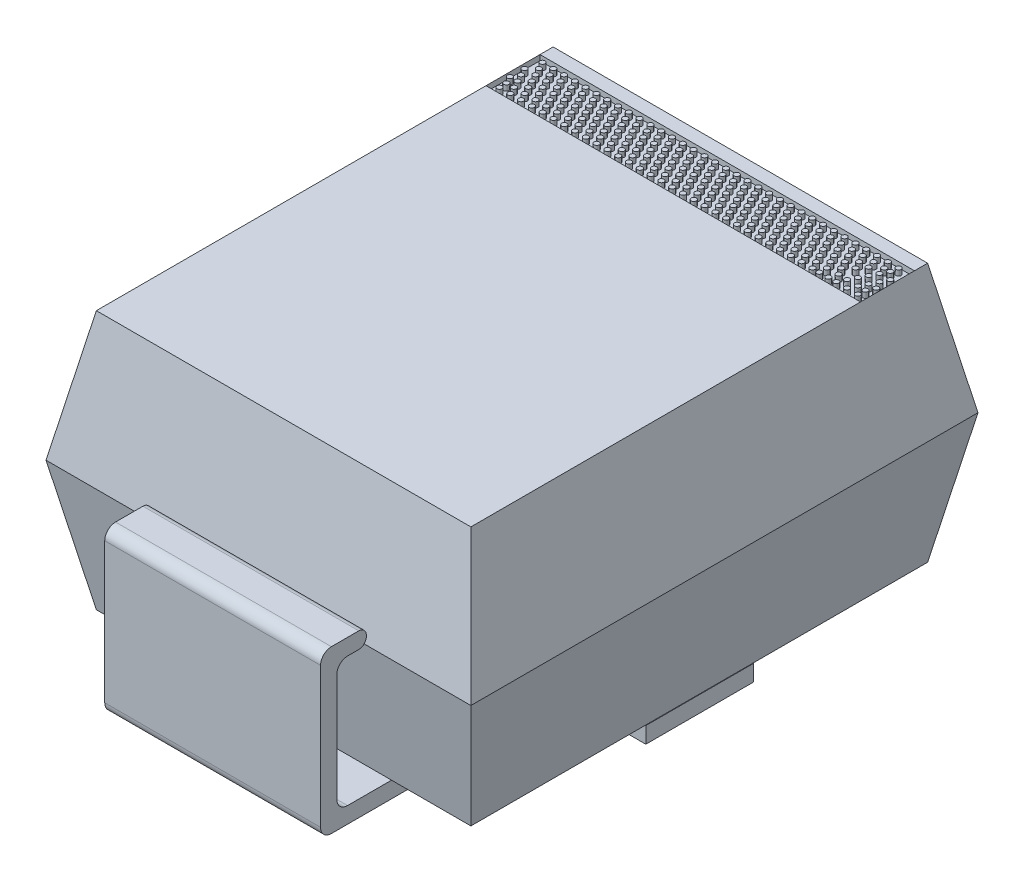
from build123d import *

# Parameters (mm, degrees)
CROQUIS9_W                        = 3.937
CROQUIS9_H                        = 4.699
SALIENTE_EXTRUIR3_DEPTH           = 1.2
SALIENTE_EXTRUIR3_TAPER           = 11
SALIENTE_EXTRUIR3_OTHER_WAY_DEPTH = 1.2
SALIENTE_EXTRUIR3_OTHER_WAY_TAPER = 11
CROQUIS10_W                       = 3.470487258
CROQUIS10_H                       = 0.5
CROQUIS10_R                       = 0.023553364
CROQUIS10_R_2                     = 0.023356671
CORTAR_EXTRUIR2_DEPTH             = 0.05
CROQUIS12_W                       = 1
CROQUIS12_H                       = 0.15
SALIENTE_EXTRUIR4_DEPTH           = 1.74
SALIENTE_EXTRUIR5_DEPTH           = 1


with BuildPart() as part:
    # Croquis9 → Saliente-Extruir3 (new body)
    with BuildSketch(Plane(origin=(0, 0, 0), x_dir=(1, 0, 0), z_dir=(0, 1, 0))):
        Rectangle(CROQUIS9_W, CROQUIS9_H)
    extrude(amount=SALIENTE_EXTRUIR3_DEPTH, taper=SALIENTE_EXTRUIR3_TAPER)

    # Croquis9 → Saliente-Extruir3 other way (add)
    with BuildSketch(Plane(origin=(0, 0, 0), x_dir=(1, 0, 0), z_dir=(0, 1, 0))):
        Rectangle(CROQUIS9_W, CROQUIS9_H)
    extrude(amount=-SALIENTE_EXTRUIR3_OTHER_WAY_DEPTH, taper=SALIENTE_EXTRUIR3_OTHER_WAY_TAPER)

    # Croquis10 → Cortar-Extruir2 (cut)
    with BuildSketch(Plane(origin=(0, 1.2, 0), x_dir=(1, 0, 0), z_dir=(0, 1, 0))):
        with Locations((0, 1.744170345)):
            Rectangle(CROQUIS10_W, CROQUIS10_H)
        with Locations((-1.6601337, 1.544634808)):
            Circle(CROQUIS10_R, mode=Mode.SUBTRACT)
        with Locations((-1.593661989, 1.611140272)):
            Circle(CROQUIS10_R, mode=Mode.SUBTRACT)
        with Locations((-1.527190278, 1.677645736)):
            Circle(CROQUIS10_R, mode=Mode.SUBTRACT)
        with Locations((-1.460718567, 1.7441512)):
            Circle(CROQUIS10_R, mode=Mode.SUBTRACT)
        with Locations((-1.394246856, 1.810656664)):
            Circle(CROQUIS10_R, mode=Mode.SUBTRACT)
        with Locations((-1.327775145, 1.877162128)):
            Circle(CROQUIS10_R, mode=Mode.SUBTRACT)
        with Locations((-1.261303434, 1.943667592)):
            Circle(CROQUIS10_R, mode=Mode.SUBTRACT)
        with Locations((-1.493661989, 1.611140272)):
            Circle(CROQUIS10_R, mode=Mode.SUBTRACT)
        with Locations((-1.5601337, 1.544634808)):
            Circle(CROQUIS10_R, mode=Mode.SUBTRACT)
        with Locations((-1.427190278, 1.677645736)):
            Circle(CROQUIS10_R, mode=Mode.SUBTRACT)
        with Locations((-1.360718567, 1.7441512)):
            Circle(CROQUIS10_R, mode=Mode.SUBTRACT)
        with Locations((-1.294246856, 1.810656664)):
            Circle(CROQUIS10_R, mode=Mode.SUBTRACT)
        with Locations((-1.227775145, 1.877162128)):
            Circle(CROQUIS10_R, mode=Mode.SUBTRACT)
        with Locations((-1.161303434, 1.943667592)):
            Circle(CROQUIS10_R, mode=Mode.SUBTRACT)
        with Locations((-1.393661989, 1.611140272)):
            Circle(CROQUIS10_R, mode=Mode.SUBTRACT)
        with Locations((-1.4601337, 1.544634808)):
            Circle(CROQUIS10_R, mode=Mode.SUBTRACT)
        with Locations((-1.327190278, 1.677645736)):
            Circle(CROQUIS10_R, mode=Mode.SUBTRACT)
        with Locations((-1.260718567, 1.7441512)):
            Circle(CROQUIS10_R, mode=Mode.SUBTRACT)
        with Locations((-1.194246856, 1.810656664)):
            Circle(CROQUIS10_R, mode=Mode.SUBTRACT)
        with Locations((-1.127775145, 1.877162128)):
            Circle(CROQUIS10_R, mode=Mode.SUBTRACT)
        with Locations((-1.061303434, 1.943667592)):
            Circle(CROQUIS10_R, mode=Mode.SUBTRACT)
        with Locations((-1.293661989, 1.611140272)):
            Circle(CROQUIS10_R, mode=Mode.SUBTRACT)
        with Locations((-1.3601337, 1.544634808)):
            Circle(CROQUIS10_R, mode=Mode.SUBTRACT)
        with Locations((-1.227190278, 1.677645736)):
            Circle(CROQUIS10_R, mode=Mode.SUBTRACT)
        with Locations((-1.160718567, 1.7441512)):
            Circle(CROQUIS10_R, mode=Mode.SUBTRACT)
        with Locations((-1.094246856, 1.810656664)):
            Circle(CROQUIS10_R, mode=Mode.SUBTRACT)
        with Locations((-1.027775145, 1.877162128)):
            Circle(CROQUIS10_R, mode=Mode.SUBTRACT)
        with Locations((-0.961303434, 1.943667592)):
            Circle(CROQUIS10_R, mode=Mode.SUBTRACT)
        with Locations((-1.193661989, 1.611140272)):
            Circle(CROQUIS10_R, mode=Mode.SUBTRACT)
        with Locations((-1.2601337, 1.544634808)):
            Circle(CROQUIS10_R, mode=Mode.SUBTRACT)
        with Locations((-1.127190278, 1.677645736)):
            Circle(CROQUIS10_R, mode=Mode.SUBTRACT)
        with Locations((-1.060718567, 1.7441512)):
            Circle(CROQUIS10_R, mode=Mode.SUBTRACT)
        with Locations((-0.994246856, 1.810656664)):
            Circle(CROQUIS10_R, mode=Mode.SUBTRACT)
        with Locations((-0.927775145, 1.877162128)):
            Circle(CROQUIS10_R, mode=Mode.SUBTRACT)
        with Locations((-0.861303434, 1.943667592)):
            Circle(CROQUIS10_R, mode=Mode.SUBTRACT)
        with Locations((-1.093661989, 1.611140272)):
            Circle(CROQUIS10_R, mode=Mode.SUBTRACT)
        with Locations((-1.1601337, 1.544634808)):
            Circle(CROQUIS10_R, mode=Mode.SUBTRACT)
        with Locations((-1.027190278, 1.677645736)):
            Circle(CROQUIS10_R, mode=Mode.SUBTRACT)
        with Locations((-0.960718567, 1.7441512)):
            Circle(CROQUIS10_R, mode=Mode.SUBTRACT)
        with Locations((-0.894246856, 1.810656664)):
            Circle(CROQUIS10_R, mode=Mode.SUBTRACT)
        with Locations((-0.827775145, 1.877162128)):
            Circle(CROQUIS10_R, mode=Mode.SUBTRACT)
        with Locations((-0.761303434, 1.943667592)):
            Circle(CROQUIS10_R, mode=Mode.SUBTRACT)
        with Locations((-0.993661989, 1.611140272)):
            Circle(CROQUIS10_R, mode=Mode.SUBTRACT)
        with Locations((-1.0601337, 1.544634808)):
            Circle(CROQUIS10_R, mode=Mode.SUBTRACT)
        with Locations((-0.927190278, 1.677645736)):
            Circle(CROQUIS10_R, mode=Mode.SUBTRACT)
        with Locations((-0.860718567, 1.7441512)):
            Circle(CROQUIS10_R, mode=Mode.SUBTRACT)
        with Locations((-0.794246856, 1.810656664)):
            Circle(CROQUIS10_R, mode=Mode.SUBTRACT)
        with Locations((-0.727775145, 1.877162128)):
            Circle(CROQUIS10_R, mode=Mode.SUBTRACT)
        with Locations((-0.661303434, 1.943667592)):
            Circle(CROQUIS10_R, mode=Mode.SUBTRACT)
        with Locations((-0.893661989, 1.611140272)):
            Circle(CROQUIS10_R, mode=Mode.SUBTRACT)
        with Locations((-0.9601337, 1.544634808)):
            Circle(CROQUIS10_R, mode=Mode.SUBTRACT)
        with Locations((-0.827190278, 1.677645736)):
            Circle(CROQUIS10_R, mode=Mode.SUBTRACT)
        with Locations((-0.760718567, 1.7441512)):
            Circle(CROQUIS10_R, mode=Mode.SUBTRACT)
        with Locations((-0.694246856, 1.810656664)):
            Circle(CROQUIS10_R, mode=Mode.SUBTRACT)
        with Locations((-0.627775145, 1.877162128)):
            Circle(CROQUIS10_R, mode=Mode.SUBTRACT)
        with Locations((-0.561303434, 1.943667592)):
            Circle(CROQUIS10_R, mode=Mode.SUBTRACT)
        with Locations((-0.793661989, 1.611140272)):
            Circle(CROQUIS10_R, mode=Mode.SUBTRACT)
        with Locations((-0.8601337, 1.544634808)):
            Circle(CROQUIS10_R, mode=Mode.SUBTRACT)
        with Locations((-0.727190278, 1.677645736)):
            Circle(CROQUIS10_R, mode=Mode.SUBTRACT)
        with Locations((-0.660718567, 1.7441512)):
            Circle(CROQUIS10_R, mode=Mode.SUBTRACT)
        with Locations((-0.594246856, 1.810656664)):
            Circle(CROQUIS10_R, mode=Mode.SUBTRACT)
        with Locations((-0.527775145, 1.877162128)):
            Circle(CROQUIS10_R, mode=Mode.SUBTRACT)
        with Locations((-0.461303434, 1.943667592)):
            Circle(CROQUIS10_R, mode=Mode.SUBTRACT)
        with Locations((-0.693661989, 1.611140272)):
            Circle(CROQUIS10_R, mode=Mode.SUBTRACT)
        with Locations((-0.7601337, 1.544634808)):
            Circle(CROQUIS10_R, mode=Mode.SUBTRACT)
        with Locations((-0.627190278, 1.677645736)):
            Circle(CROQUIS10_R, mode=Mode.SUBTRACT)
        with Locations((-0.560718567, 1.7441512)):
            Circle(CROQUIS10_R, mode=Mode.SUBTRACT)
        with Locations((-0.494246856, 1.810656664)):
            Circle(CROQUIS10_R, mode=Mode.SUBTRACT)
        with Locations((-0.427775145, 1.877162128)):
            Circle(CROQUIS10_R, mode=Mode.SUBTRACT)
        with Locations((-0.361303434, 1.943667592)):
            Circle(CROQUIS10_R, mode=Mode.SUBTRACT)
        with Locations((-0.593661989, 1.611140272)):
            Circle(CROQUIS10_R, mode=Mode.SUBTRACT)
        with Locations((-0.6601337, 1.544634808)):
            Circle(CROQUIS10_R, mode=Mode.SUBTRACT)
        with Locations((-0.527190278, 1.677645736)):
            Circle(CROQUIS10_R, mode=Mode.SUBTRACT)
        with Locations((-0.460718567, 1.7441512)):
            Circle(CROQUIS10_R, mode=Mode.SUBTRACT)
        with Locations((-0.394246856, 1.810656664)):
            Circle(CROQUIS10_R, mode=Mode.SUBTRACT)
        with Locations((-0.327775145, 1.877162128)):
            Circle(CROQUIS10_R, mode=Mode.SUBTRACT)
        with Locations((-0.261303434, 1.943667592)):
            Circle(CROQUIS10_R, mode=Mode.SUBTRACT)
        with Locations((-0.493661989, 1.611140272)):
            Circle(CROQUIS10_R, mode=Mode.SUBTRACT)
        with Locations((-0.5601337, 1.544634808)):
            Circle(CROQUIS10_R, mode=Mode.SUBTRACT)
        with Locations((-0.427190278, 1.677645736)):
            Circle(CROQUIS10_R, mode=Mode.SUBTRACT)
        with Locations((-0.360718567, 1.7441512)):
            Circle(CROQUIS10_R, mode=Mode.SUBTRACT)
        with Locations((-0.294246856, 1.810656664)):
            Circle(CROQUIS10_R, mode=Mode.SUBTRACT)
        with Locations((-0.227775145, 1.877162128)):
            Circle(CROQUIS10_R, mode=Mode.SUBTRACT)
        with Locations((-0.161303434, 1.943667592)):
            Circle(CROQUIS10_R, mode=Mode.SUBTRACT)
        with Locations((-0.393661989, 1.611140272)):
            Circle(CROQUIS10_R, mode=Mode.SUBTRACT)
        with Locations((-0.4601337, 1.544634808)):
            Circle(CROQUIS10_R, mode=Mode.SUBTRACT)
        with Locations((-0.327190278, 1.677645736)):
            Circle(CROQUIS10_R, mode=Mode.SUBTRACT)
        with Locations((-0.260718567, 1.7441512)):
            Circle(CROQUIS10_R, mode=Mode.SUBTRACT)
        with Locations((-0.194246856, 1.810656664)):
            Circle(CROQUIS10_R, mode=Mode.SUBTRACT)
        with Locations((-0.127775145, 1.877162128)):
            Circle(CROQUIS10_R, mode=Mode.SUBTRACT)
        with Locations((-0.061303434, 1.943667592)):
            Circle(CROQUIS10_R, mode=Mode.SUBTRACT)
        with Locations((-0.293661989, 1.611140272)):
            Circle(CROQUIS10_R, mode=Mode.SUBTRACT)
        with Locations((-0.3601337, 1.544634808)):
            Circle(CROQUIS10_R, mode=Mode.SUBTRACT)
        with Locations((-0.227190278, 1.677645736)):
            Circle(CROQUIS10_R, mode=Mode.SUBTRACT)
        with Locations((-0.160718567, 1.7441512)):
            Circle(CROQUIS10_R, mode=Mode.SUBTRACT)
        with Locations((-0.094246856, 1.810656664)):
            Circle(CROQUIS10_R, mode=Mode.SUBTRACT)
        with Locations((-0.027775145, 1.877162128)):
            Circle(CROQUIS10_R, mode=Mode.SUBTRACT)
        with Locations((0.038696566, 1.943667592)):
            Circle(CROQUIS10_R, mode=Mode.SUBTRACT)
        with Locations((-0.193661989, 1.611140272)):
            Circle(CROQUIS10_R, mode=Mode.SUBTRACT)
        with Locations((-0.2601337, 1.544634808)):
            Circle(CROQUIS10_R, mode=Mode.SUBTRACT)
        with Locations((-0.127190278, 1.677645736)):
            Circle(CROQUIS10_R, mode=Mode.SUBTRACT)
        with Locations((-0.060718567, 1.7441512)):
            Circle(CROQUIS10_R, mode=Mode.SUBTRACT)
        with Locations((0.005753144, 1.810656664)):
            Circle(CROQUIS10_R, mode=Mode.SUBTRACT)
        with Locations((0.072224855, 1.877162128)):
            Circle(CROQUIS10_R, mode=Mode.SUBTRACT)
        with Locations((0.138696566, 1.943667592)):
            Circle(CROQUIS10_R, mode=Mode.SUBTRACT)
        with Locations((-0.093661989, 1.611140272)):
            Circle(CROQUIS10_R, mode=Mode.SUBTRACT)
        with Locations((-0.1601337, 1.544634808)):
            Circle(CROQUIS10_R, mode=Mode.SUBTRACT)
        with Locations((-0.027190278, 1.677645736)):
            Circle(CROQUIS10_R, mode=Mode.SUBTRACT)
        with Locations((0.039281433, 1.7441512)):
            Circle(CROQUIS10_R, mode=Mode.SUBTRACT)
        with Locations((0.105753144, 1.810656664)):
            Circle(CROQUIS10_R, mode=Mode.SUBTRACT)
        with Locations((0.172224855, 1.877162128)):
            Circle(CROQUIS10_R, mode=Mode.SUBTRACT)
        with Locations((0.238696566, 1.943667592)):
            Circle(CROQUIS10_R, mode=Mode.SUBTRACT)
        with Locations((0.006338011, 1.611140272)):
            Circle(CROQUIS10_R, mode=Mode.SUBTRACT)
        with Locations((-0.0601337, 1.544634808)):
            Circle(CROQUIS10_R, mode=Mode.SUBTRACT)
        with Locations((0.072809722, 1.677645736)):
            Circle(CROQUIS10_R, mode=Mode.SUBTRACT)
        with Locations((0.139281433, 1.7441512)):
            Circle(CROQUIS10_R, mode=Mode.SUBTRACT)
        with Locations((0.205753144, 1.810656664)):
            Circle(CROQUIS10_R, mode=Mode.SUBTRACT)
        with Locations((0.272224855, 1.877162128)):
            Circle(CROQUIS10_R, mode=Mode.SUBTRACT)
        with Locations((0.338696566, 1.943667592)):
            Circle(CROQUIS10_R, mode=Mode.SUBTRACT)
        with Locations((0.106338011, 1.611140272)):
            Circle(CROQUIS10_R, mode=Mode.SUBTRACT)
        with Locations((0.0398663, 1.544634808)):
            Circle(CROQUIS10_R, mode=Mode.SUBTRACT)
        with Locations((0.172809722, 1.677645736)):
            Circle(CROQUIS10_R, mode=Mode.SUBTRACT)
        with Locations((0.239281433, 1.7441512)):
            Circle(CROQUIS10_R, mode=Mode.SUBTRACT)
        with Locations((0.305753144, 1.810656664)):
            Circle(CROQUIS10_R, mode=Mode.SUBTRACT)
        with Locations((0.372224855, 1.877162128)):
            Circle(CROQUIS10_R, mode=Mode.SUBTRACT)
        with Locations((0.438696566, 1.943667592)):
            Circle(CROQUIS10_R, mode=Mode.SUBTRACT)
        with Locations((0.206338011, 1.611140272)):
            Circle(CROQUIS10_R, mode=Mode.SUBTRACT)
        with Locations((0.1398663, 1.544634808)):
            Circle(CROQUIS10_R, mode=Mode.SUBTRACT)
        with Locations((0.272809722, 1.677645736)):
            Circle(CROQUIS10_R, mode=Mode.SUBTRACT)
        with Locations((0.339281433, 1.7441512)):
            Circle(CROQUIS10_R, mode=Mode.SUBTRACT)
        with Locations((0.405753144, 1.810656664)):
            Circle(CROQUIS10_R, mode=Mode.SUBTRACT)
        with Locations((0.472224855, 1.877162128)):
            Circle(CROQUIS10_R, mode=Mode.SUBTRACT)
        with Locations((0.538696566, 1.943667592)):
            Circle(CROQUIS10_R, mode=Mode.SUBTRACT)
        with Locations((0.306338011, 1.611140272)):
            Circle(CROQUIS10_R, mode=Mode.SUBTRACT)
        with Locations((0.2398663, 1.544634808)):
            Circle(CROQUIS10_R, mode=Mode.SUBTRACT)
        with Locations((0.372809722, 1.677645736)):
            Circle(CROQUIS10_R, mode=Mode.SUBTRACT)
        with Locations((0.439281433, 1.7441512)):
            Circle(CROQUIS10_R, mode=Mode.SUBTRACT)
        with Locations((0.505753144, 1.810656664)):
            Circle(CROQUIS10_R, mode=Mode.SUBTRACT)
        with Locations((0.572224855, 1.877162128)):
            Circle(CROQUIS10_R, mode=Mode.SUBTRACT)
        with Locations((0.638696566, 1.943667592)):
            Circle(CROQUIS10_R, mode=Mode.SUBTRACT)
        with Locations((0.406338011, 1.611140272)):
            Circle(CROQUIS10_R, mode=Mode.SUBTRACT)
        with Locations((0.3398663, 1.544634808)):
            Circle(CROQUIS10_R, mode=Mode.SUBTRACT)
        with Locations((0.472809722, 1.677645736)):
            Circle(CROQUIS10_R, mode=Mode.SUBTRACT)
        with Locations((0.539281433, 1.7441512)):
            Circle(CROQUIS10_R, mode=Mode.SUBTRACT)
        with Locations((0.605753144, 1.810656664)):
            Circle(CROQUIS10_R, mode=Mode.SUBTRACT)
        with Locations((0.672224855, 1.877162128)):
            Circle(CROQUIS10_R, mode=Mode.SUBTRACT)
        with Locations((0.738696566, 1.943667592)):
            Circle(CROQUIS10_R, mode=Mode.SUBTRACT)
        with Locations((0.506338011, 1.611140272)):
            Circle(CROQUIS10_R, mode=Mode.SUBTRACT)
        with Locations((0.4398663, 1.544634808)):
            Circle(CROQUIS10_R, mode=Mode.SUBTRACT)
        with Locations((0.572809722, 1.677645736)):
            Circle(CROQUIS10_R, mode=Mode.SUBTRACT)
        with Locations((0.639281433, 1.7441512)):
            Circle(CROQUIS10_R, mode=Mode.SUBTRACT)
        with Locations((0.705753144, 1.810656664)):
            Circle(CROQUIS10_R, mode=Mode.SUBTRACT)
        with Locations((0.772224855, 1.877162128)):
            Circle(CROQUIS10_R, mode=Mode.SUBTRACT)
        with Locations((0.838696566, 1.943667592)):
            Circle(CROQUIS10_R, mode=Mode.SUBTRACT)
        with Locations((0.606338011, 1.611140272)):
            Circle(CROQUIS10_R, mode=Mode.SUBTRACT)
        with Locations((0.5398663, 1.544634808)):
            Circle(CROQUIS10_R, mode=Mode.SUBTRACT)
        with Locations((0.672809722, 1.677645736)):
            Circle(CROQUIS10_R, mode=Mode.SUBTRACT)
        with Locations((0.739281433, 1.7441512)):
            Circle(CROQUIS10_R, mode=Mode.SUBTRACT)
        with Locations((0.805753144, 1.810656664)):
            Circle(CROQUIS10_R, mode=Mode.SUBTRACT)
        with Locations((0.872224855, 1.877162128)):
            Circle(CROQUIS10_R, mode=Mode.SUBTRACT)
        with Locations((0.938696566, 1.943667592)):
            Circle(CROQUIS10_R, mode=Mode.SUBTRACT)
        with Locations((0.706338011, 1.611140272)):
            Circle(CROQUIS10_R, mode=Mode.SUBTRACT)
        with Locations((0.6398663, 1.544634808)):
            Circle(CROQUIS10_R, mode=Mode.SUBTRACT)
        with Locations((0.772809722, 1.677645736)):
            Circle(CROQUIS10_R, mode=Mode.SUBTRACT)
        with Locations((0.839281433, 1.7441512)):
            Circle(CROQUIS10_R, mode=Mode.SUBTRACT)
        with Locations((0.905753144, 1.810656664)):
            Circle(CROQUIS10_R, mode=Mode.SUBTRACT)
        with Locations((0.972224855, 1.877162128)):
            Circle(CROQUIS10_R, mode=Mode.SUBTRACT)
        with Locations((1.038696566, 1.943667592)):
            Circle(CROQUIS10_R, mode=Mode.SUBTRACT)
        with Locations((0.806338011, 1.611140272)):
            Circle(CROQUIS10_R, mode=Mode.SUBTRACT)
        with Locations((0.7398663, 1.544634808)):
            Circle(CROQUIS10_R, mode=Mode.SUBTRACT)
        with Locations((0.872809722, 1.677645736)):
            Circle(CROQUIS10_R, mode=Mode.SUBTRACT)
        with Locations((0.939281433, 1.7441512)):
            Circle(CROQUIS10_R, mode=Mode.SUBTRACT)
        with Locations((1.005753144, 1.810656664)):
            Circle(CROQUIS10_R, mode=Mode.SUBTRACT)
        with Locations((1.072224855, 1.877162128)):
            Circle(CROQUIS10_R, mode=Mode.SUBTRACT)
        with Locations((1.138696566, 1.943667592)):
            Circle(CROQUIS10_R, mode=Mode.SUBTRACT)
        with Locations((0.906338011, 1.611140272)):
            Circle(CROQUIS10_R, mode=Mode.SUBTRACT)
        with Locations((0.8398663, 1.544634808)):
            Circle(CROQUIS10_R, mode=Mode.SUBTRACT)
        with Locations((0.972809722, 1.677645736)):
            Circle(CROQUIS10_R, mode=Mode.SUBTRACT)
        with Locations((1.039281433, 1.7441512)):
            Circle(CROQUIS10_R, mode=Mode.SUBTRACT)
        with Locations((1.105753144, 1.810656664)):
            Circle(CROQUIS10_R, mode=Mode.SUBTRACT)
        with Locations((1.172224855, 1.877162128)):
            Circle(CROQUIS10_R, mode=Mode.SUBTRACT)
        with Locations((1.238696566, 1.943667592)):
            Circle(CROQUIS10_R, mode=Mode.SUBTRACT)
        with Locations((1.006338011, 1.611140272)):
            Circle(CROQUIS10_R, mode=Mode.SUBTRACT)
        with Locations((0.9398663, 1.544634808)):
            Circle(CROQUIS10_R, mode=Mode.SUBTRACT)
        with Locations((1.072809722, 1.677645736)):
            Circle(CROQUIS10_R, mode=Mode.SUBTRACT)
        with Locations((1.139281433, 1.7441512)):
            Circle(CROQUIS10_R, mode=Mode.SUBTRACT)
        with Locations((1.205753144, 1.810656664)):
            Circle(CROQUIS10_R, mode=Mode.SUBTRACT)
        with Locations((1.272224855, 1.877162128)):
            Circle(CROQUIS10_R, mode=Mode.SUBTRACT)
        with Locations((1.338696566, 1.943667592)):
            Circle(CROQUIS10_R, mode=Mode.SUBTRACT)
        with Locations((1.106338011, 1.611140272)):
            Circle(CROQUIS10_R, mode=Mode.SUBTRACT)
        with Locations((1.0398663, 1.544634808)):
            Circle(CROQUIS10_R, mode=Mode.SUBTRACT)
        with Locations((1.172809722, 1.677645736)):
            Circle(CROQUIS10_R, mode=Mode.SUBTRACT)
        with Locations((1.239281433, 1.7441512)):
            Circle(CROQUIS10_R, mode=Mode.SUBTRACT)
        with Locations((1.305753144, 1.810656664)):
            Circle(CROQUIS10_R, mode=Mode.SUBTRACT)
        with Locations((1.372224855, 1.877162128)):
            Circle(CROQUIS10_R, mode=Mode.SUBTRACT)
        with Locations((1.438696566, 1.943667592)):
            Circle(CROQUIS10_R, mode=Mode.SUBTRACT)
        with Locations((1.206338011, 1.611140272)):
            Circle(CROQUIS10_R, mode=Mode.SUBTRACT)
        with Locations((1.1398663, 1.544634808)):
            Circle(CROQUIS10_R, mode=Mode.SUBTRACT)
        with Locations((1.272809722, 1.677645736)):
            Circle(CROQUIS10_R, mode=Mode.SUBTRACT)
        with Locations((1.339281433, 1.7441512)):
            Circle(CROQUIS10_R, mode=Mode.SUBTRACT)
        with Locations((1.405753144, 1.810656664)):
            Circle(CROQUIS10_R, mode=Mode.SUBTRACT)
        with Locations((1.472224855, 1.877162128)):
            Circle(CROQUIS10_R, mode=Mode.SUBTRACT)
        with Locations((1.538696566, 1.943667592)):
            Circle(CROQUIS10_R, mode=Mode.SUBTRACT)
        with Locations((1.306338011, 1.611140272)):
            Circle(CROQUIS10_R, mode=Mode.SUBTRACT)
        with Locations((1.2398663, 1.544634808)):
            Circle(CROQUIS10_R, mode=Mode.SUBTRACT)
        with Locations((1.372809722, 1.677645736)):
            Circle(CROQUIS10_R, mode=Mode.SUBTRACT)
        with Locations((1.439281433, 1.7441512)):
            Circle(CROQUIS10_R, mode=Mode.SUBTRACT)
        with Locations((1.305753144, 1.541401411)):
            Circle(CROQUIS10_R, mode=Mode.SUBTRACT)
        with Locations((1.572224855, 1.877162128)):
            Circle(CROQUIS10_R, mode=Mode.SUBTRACT)
        with Locations((1.638696566, 1.943667592)):
            Circle(CROQUIS10_R, mode=Mode.SUBTRACT)
        with Locations((-1.427775145, 1.877162128)):
            Circle(CROQUIS10_R, mode=Mode.SUBTRACT)
        with Locations((-1.361303434, 1.943667592)):
            Circle(CROQUIS10_R, mode=Mode.SUBTRACT)
        with Locations((-1.494246856, 1.810656664)):
            Circle(CROQUIS10_R, mode=Mode.SUBTRACT)
        with Locations((-1.560718567, 1.7441512)):
            Circle(CROQUIS10_R, mode=Mode.SUBTRACT)
        with Locations((-1.527775145, 1.877162128)):
            Circle(CROQUIS10_R, mode=Mode.SUBTRACT)
        with Locations((-1.461303434, 1.943667592)):
            Circle(CROQUIS10_R, mode=Mode.SUBTRACT)
        with Locations((-1.594246856, 1.810656664)):
            Circle(CROQUIS10_R, mode=Mode.SUBTRACT)
        with Locations((-1.694246856, 1.810656664)):
            Circle(CROQUIS10_R, mode=Mode.SUBTRACT)
        with Locations((-1.660718567, 1.7441512)):
            Circle(CROQUIS10_R, mode=Mode.SUBTRACT)
        with Locations((-1.627775145, 1.877162128)):
            Circle(CROQUIS10_R, mode=Mode.SUBTRACT)
        with Locations((-1.561303434, 1.943667592)):
            Circle(CROQUIS10_R, mode=Mode.SUBTRACT)
        with Locations((-1.627190278, 1.677645736)):
            Circle(CROQUIS10_R, mode=Mode.SUBTRACT)
        with Locations((-1.661303434, 1.943667592)):
            Circle(CROQUIS10_R, mode=Mode.SUBTRACT)
        with Locations((-1.697190278, 1.677645736)):
            Circle(CROQUIS10_R, mode=Mode.SUBTRACT)
        with Locations((-1.663661989, 1.611140272)):
            Circle(CROQUIS10_R, mode=Mode.SUBTRACT)
        with Locations((1.38726301, 1.544634808)):
            Circle(CROQUIS10_R, mode=Mode.SUBTRACT)
        with Locations((1.663661989, 1.611140272)):
            Circle(CROQUIS10_R_2, mode=Mode.SUBTRACT)
        with Locations((1.697190278, 1.677645736)):
            Circle(CROQUIS10_R_2, mode=Mode.SUBTRACT)
        with Locations((1.410816374, 1.616054362)):
            Circle(CROQUIS10_R, mode=Mode.SUBTRACT)
        with Locations((1.627190278, 1.677645736)):
            Circle(CROQUIS10_R_2, mode=Mode.SUBTRACT)
        with Locations((1.627775145, 1.877162128)):
            Circle(CROQUIS10_R_2, mode=Mode.SUBTRACT)
        with Locations((1.660718567, 1.7441512)):
            Circle(CROQUIS10_R_2, mode=Mode.SUBTRACT)
        with Locations((1.694246856, 1.810656664)):
            Circle(CROQUIS10_R_2, mode=Mode.SUBTRACT)
        with Locations((1.560718567, 1.7441512)):
            Circle(CROQUIS10_R_2, mode=Mode.SUBTRACT)
        with Locations((1.594246856, 1.810656664)):
            Circle(CROQUIS10_R_2, mode=Mode.SUBTRACT)
        with Locations((1.494246856, 1.810656664)):
            Circle(CROQUIS10_R_2, mode=Mode.SUBTRACT)
        with Locations((1.4601337, 1.544634808)):
            Circle(CROQUIS10_R_2, mode=Mode.SUBTRACT)
        with Locations((1.5601337, 1.544634808)):
            Circle(CROQUIS10_R_2, mode=Mode.SUBTRACT)
        with Locations((1.493661989, 1.611140272)):
            Circle(CROQUIS10_R_2, mode=Mode.SUBTRACT)
        with Locations((1.527190278, 1.677645736)):
            Circle(CROQUIS10_R_2, mode=Mode.SUBTRACT)
        with Locations((1.593661989, 1.611140272)):
            Circle(CROQUIS10_R_2, mode=Mode.SUBTRACT)
        with Locations((1.6601337, 1.544634808)):
            Circle(CROQUIS10_R_2, mode=Mode.SUBTRACT)
    extrude(amount=-CORTAR_EXTRUIR2_DEPTH, mode=Mode.SUBTRACT)

    # Croquis12 → Saliente-Extruir4 (add, symmetric)
    with BuildSketch(Plane(origin=(0, 0, 0), x_dir=(0, 0, -1), z_dir=(1, 0, 0))):
        with Locations((0, -1.275)):
            Rectangle(CROQUIS12_W, CROQUIS12_H)
    extrude(amount=SALIENTE_EXTRUIR4_DEPTH, both=True)

    # Croquis15 → Saliente-Extruir5 (add, symmetric)
    with BuildSketch(Plane(origin=(0, 0, 0), x_dir=(0, 0, -1), z_dir=(1, 0, 0))):
        with BuildLine():
            ThreePointArc((-2.4195, 0.15), (-2.370002525, 0.129497475), (-2.3495, 0.08))
            Line((-2.3495, 0.08), (-2.3495, 0.07))
            ThreePointArc((-2.3495, 0.07), (-2.370002525, 0.020502525), (-2.4195, 0))
            Line((-2.4195, 0), (-2.523753497, 0))
            ThreePointArc((-2.523753497, 0), (-2.594464175, -0.029289322), (-2.623753497, -0.1))
            Line((-2.623753497, -0.1), (-2.623753497, -1.1))
            ThreePointArc((-2.623753497, -1.1), (-2.594464175, -1.170710678), (-2.523753497, -1.2))
            Line((-2.523753497, -1.2), (-1.675611756, -1.2))
            ThreePointArc((-1.675611756, -1.2), (-1.626114281, -1.220502525), (-1.605611756, -1.27))
            Line((-1.605611756, -1.27), (-1.605611756, -1.28))
            ThreePointArc((-1.605611756, -1.28), (-1.626114281, -1.329497475), (-1.675611756, -1.35))
            Line((-1.675611756, -1.35), (-2.673753497, -1.35))
            ThreePointArc((-2.673753497, -1.35), (-2.744464175, -1.320710678), (-2.773753497, -1.25))
            Line((-2.773753497, -1.25), (-2.773753497, 0))
            Line((-2.773753497, 0), (-2.773753497, 0.05))
            ThreePointArc((-2.773753497, 0.05), (-2.744464175, 0.120710678), (-2.673753497, 0.15))
            Line((-2.673753497, 0.15), (-2.4195, 0.15))
        make_face()
        with BuildLine():
            Line((2.3495, 0.08), (2.3495, 0.07))
            ThreePointArc((2.3495, 0.07), (2.370002525, 0.020502525), (2.4195, 0))
            Line((2.4195, 0), (2.523753497, 0))
            ThreePointArc((2.523753497, 0), (2.594464175, -0.029289322), (2.623753497, -0.1))
            Line((2.623753497, -0.1), (2.623753497, -1.1))
            ThreePointArc((2.623753497, -1.1), (2.594464175, -1.170710678), (2.523753497, -1.2))
            Line((2.523753497, -1.2), (1.675611756, -1.2))
            ThreePointArc((1.675611756, -1.2), (1.626114281, -1.220502525), (1.605611756, -1.27))
            Line((1.605611756, -1.27), (1.605611756, -1.28))
            ThreePointArc((1.605611756, -1.28), (1.626114281, -1.329497475), (1.675611756, -1.35))
            Line((1.675611756, -1.35), (2.623753497, -1.35))
            Line((2.623753497, -1.35), (2.673753497, -1.35))
            ThreePointArc((2.673753497, -1.35), (2.744464175, -1.320710678), (2.773753497, -1.25))
            Line((2.773753497, -1.25), (2.773753497, 0))
            Line((2.773753497, 0), (2.773753497, 0.05))
            ThreePointArc((2.773753497, 0.05), (2.744464175, 0.120710678), (2.673753497, 0.15))
            Line((2.673753497, 0.15), (2.4195, 0.15))
            ThreePointArc((2.4195, 0.15), (2.370002525, 0.129497475), (2.3495, 0.08))
        make_face()
    extrude(amount=SALIENTE_EXTRUIR5_DEPTH, both=True)


solid = part.part
